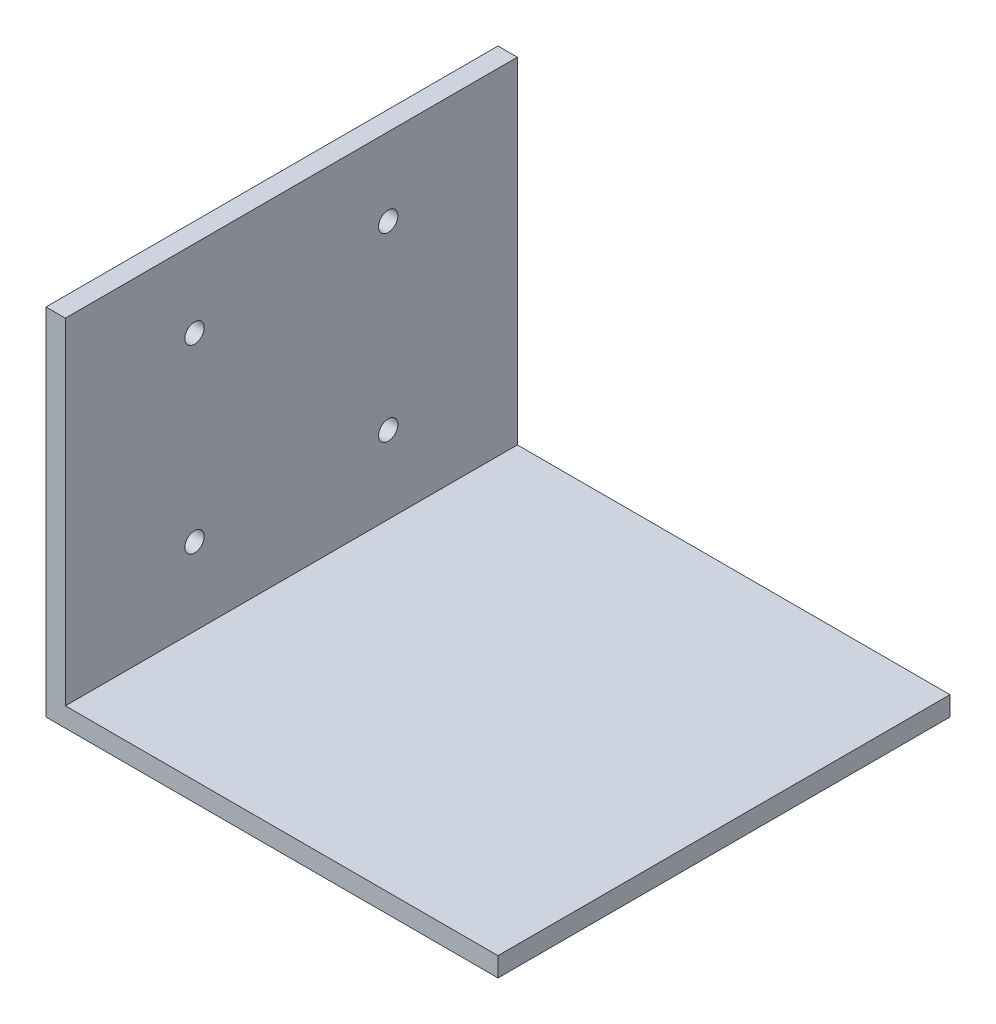
from build123d import *

# Parameters (mm, degrees)
BOSS_EXTRUDE1_DEPTH = 70
SKETCH2_R           = 1.5
CUT_EXTRUDE1_DEPTH  = 70


with BuildPart() as part:
    # Sketch1 → Boss-Extrude1 (new body)
    with BuildSketch(Plane.XY):
        Polygon((0, 0), (0, 55), (3, 55), (3, 3), (70, 3), (70, 0), align=None)
    extrude(amount=BOSS_EXTRUDE1_DEPTH)

    # Sketch2 → Cut-Extrude1 (cut)
    with BuildSketch(Plane(origin=(3, 0, 0), x_dir=(0, 0, -1), z_dir=(1, 0, 0))):
        with Locations((-50, 43)):
            Circle(SKETCH2_R)
        with Locations((-20, 43)):
            Circle(SKETCH2_R)
        with Locations((-20, 15)):
            Circle(SKETCH2_R)
        with Locations((-50, 15)):
            Circle(SKETCH2_R)
    extrude(amount=-CUT_EXTRUDE1_DEPTH, mode=Mode.SUBTRACT)


solid = part.part
